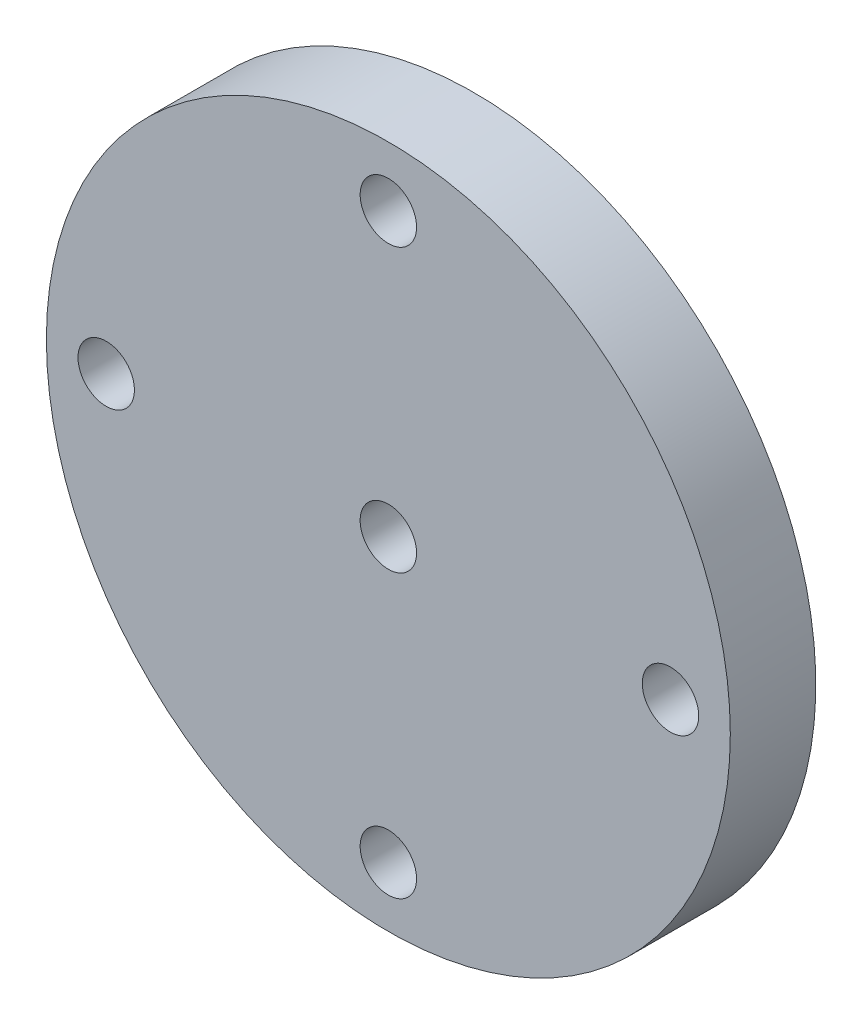
from build123d import *

# Parameters (mm, degrees)
SKETCH1_R             = 20
BOSS_EXTRUDE1_DEPTH   = 10
SKETCH2_W             = 10
SKETCH2_H             = 10
CUT_EXTRUDE1_DEPTH    = 5
M4X0_7_TAPPED_HOLE1_D = 3.3
SKETCH6_R             = 20
SKETCH6_R_2           = 12.5
CUT_EXTRUDE2_DEPTH    = 5
M4X0_7_TAPPED_HOLE2_D = 3.3


with BuildPart() as part:
    # Sketch1 → Boss-Extrude1 (new body)
    with BuildSketch(Plane.XY):
        Circle(SKETCH1_R)
    extrude(amount=BOSS_EXTRUDE1_DEPTH)

    # Sketch2 → Cut-Extrude1 (cut)
    with BuildSketch(Plane(origin=(0, 0, 0), x_dir=(-1, 0, 0), z_dir=(0, 0, -1))):
        Rectangle(SKETCH2_W, SKETCH2_H)
    extrude(amount=-CUT_EXTRUDE1_DEPTH, mode=Mode.SUBTRACT)

    # M4x0.7 Tapped Hole1 (through all)
    with Locations(Plane.XY.offset(10)):
        with Locations((0, 0)):
            Hole(M4X0_7_TAPPED_HOLE1_D / 2)

    # Sketch6 → Cut-Extrude2 (cut)
    with BuildSketch(Plane(origin=(0, 0, 0), x_dir=(-1, 0, 0), z_dir=(0, 0, -1))):
        Circle(SKETCH6_R)
        Circle(SKETCH6_R_2, mode=Mode.SUBTRACT)
    extrude(amount=-CUT_EXTRUDE2_DEPTH, mode=Mode.SUBTRACT)

    # M4x0.7 Tapped Hole2 (through all)
    with Locations(Plane(origin=(0, 0, 5), x_dir=(-1, 0, 0), z_dir=(0, 0, -1))):
        with Locations((0, 16.5), (16.5, 0), (0, -16.5), (0, 0), (-16.5, 0)):
            Hole(M4X0_7_TAPPED_HOLE2_D / 2)


solid = part.part
